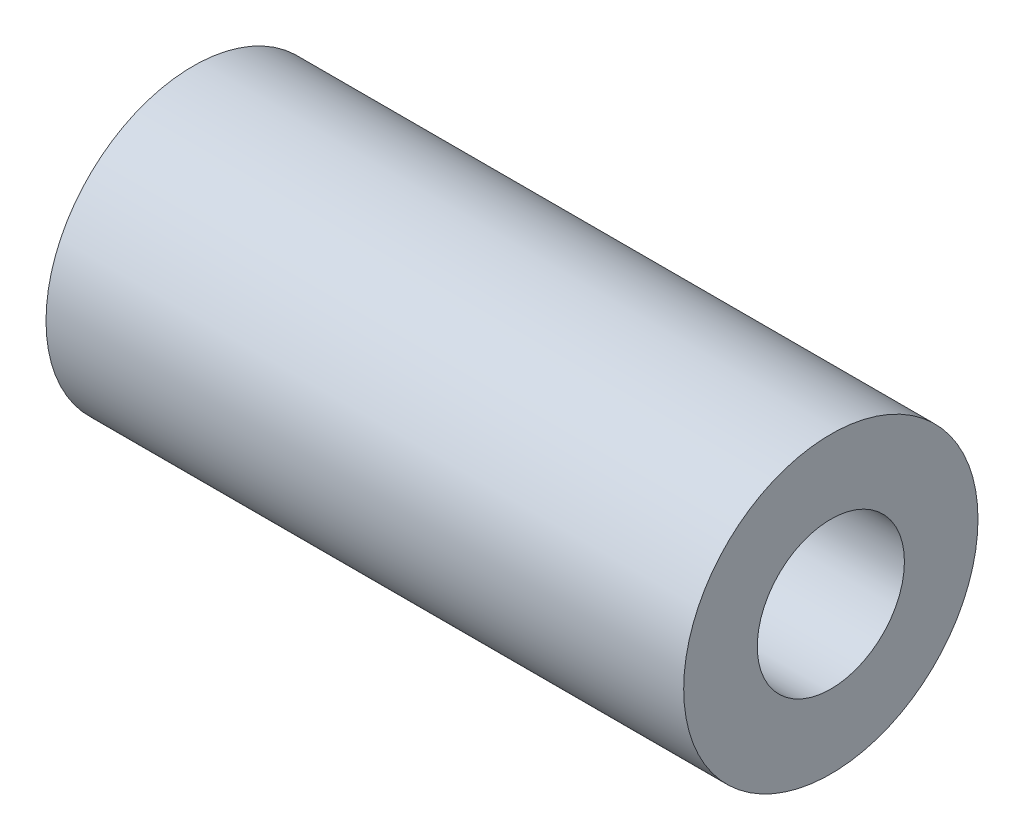
from build123d import *

# Parameters (mm, degrees)
SKETCH_1_R      = 3
SKETCH_1_R_2    = 1.5
EXTRUDE_1_DEPTH = 13


with BuildPart() as part:
    # 草图1 → 凸台-拉伸1 (new body)
    with BuildSketch(Plane(origin=(0, 0, 0), x_dir=(0, 0, -1), z_dir=(1, 0, 0))):
        Circle(SKETCH_1_R)
        Circle(SKETCH_1_R_2, mode=Mode.SUBTRACT)
    extrude(amount=EXTRUDE_1_DEPTH)


solid = part.part
